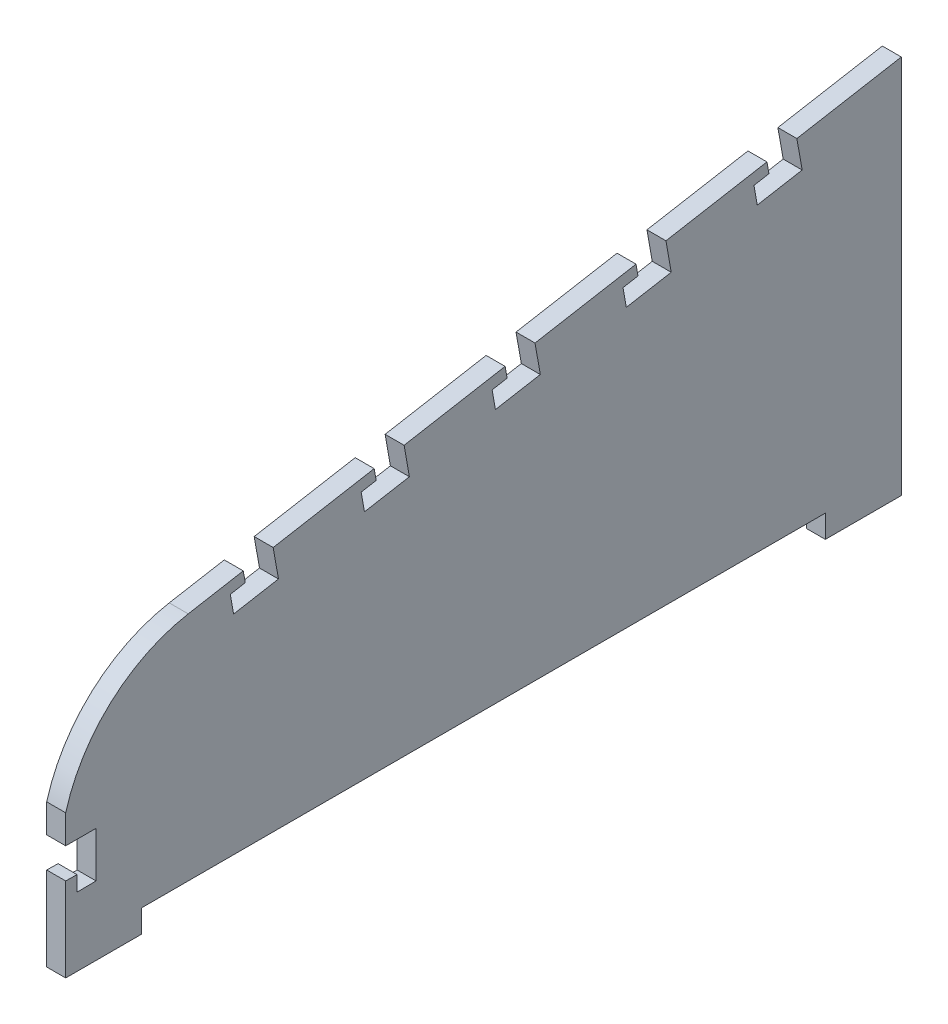
from build123d import *

# Parameters (mm, degrees)
BOSS_EXTRUDE1_DEPTH = 5


with BuildPart() as part:
    # Sketch1 → Boss-Extrude1 (new body)
    with BuildSketch(Plane(origin=(0, 0, 0), x_dir=(0, 0, -1), z_dir=(1, 0, 0))):
        with BuildLine():
            Line((-110, -6), (-90, -6))
            Line((-90, -6), (-90, 0))
            Line((-90, 0), (90, 0))
            Line((90, 0), (90, -6))
            Line((90, -6), (110, -6))
            Line((110, -6), (110, 94))
            Line((110, 94), (82.504621365, 89.151822902))
            Line((82.504621365, 89.151822902), (83.893806786, 81.273360878))
            Line((83.893806786, 81.273360878), (72.07611375, 79.189582746))
            Line((72.07611375, 79.189582746), (71.207872862, 84.113621511))
            Line((71.207872862, 84.113621511), (75.147103874, 84.808214222))
            Line((75.147103874, 84.808214222), (74.626159341, 87.762637481))
            Line((74.626159341, 87.762637481), (48.03635001, 83.074136684))
            Line((48.03635001, 83.074136684), (49.425535431, 75.195674659))
            Line((49.425535431, 75.195674659), (37.607842395, 73.111896527))
            Line((37.607842395, 73.111896527), (36.739601507, 78.035935292))
            Line((36.739601507, 78.035935292), (40.678832519, 78.730528003))
            Line((40.678832519, 78.730528003), (40.157887986, 81.684951262))
            Line((40.157887986, 81.684951262), (13.568078654, 76.996450465))
            Line((13.568078654, 76.996450465), (14.957264076, 69.117988441))
            Line((14.957264076, 69.117988441), (3.139571039, 67.034210309))
            Line((3.139571039, 67.034210309), (2.271330151, 71.958249074))
            Line((2.271330151, 71.958249074), (6.210561163, 72.652841785))
            Line((6.210561163, 72.652841785), (5.68961663, 75.607265044))
            Line((5.68961663, 75.607265044), (-20.900192701, 70.918764247))
            Line((-20.900192701, 70.918764247), (-19.51100728, 63.040302223))
            Line((-19.51100728, 63.040302223), (-31.328700316, 60.956524091))
            Line((-31.328700316, 60.956524091), (-32.196941204, 65.880562856))
            Line((-32.196941204, 65.880562856), (-28.257710192, 66.575155566))
            Line((-28.257710192, 66.575155566), (-28.778654725, 69.529578826))
            Line((-28.778654725, 69.529578826), (-55.368464057, 64.841078029))
            Line((-55.368464057, 64.841078029), (-53.979278635, 56.962616004))
            Line((-53.979278635, 56.962616004), (-65.796971671, 54.878837872))
            Line((-65.796971671, 54.878837872), (-66.66521256, 59.802876637))
            Line((-66.66521256, 59.802876637), (-62.725981548, 60.497469348))
            Line((-62.725981548, 60.497469348), (-63.246926081, 63.451892607))
            Line((-63.246926081, 63.451892607), (-77.735825896, 60.897108649))
            ThreePointArc((-77.735825896, 60.897108649), (-98.082925814, 50.934591362), (-110, 31.66701319))
            Line((-110, 31.66701319), (-110, 24.130960335))
            Line((-110, 24.130960335), (-102, 24.130960335))
            Line((-102, 24.130960335), (-102, 12.130960335))
            Line((-102, 12.130960335), (-106.999710258, 12.07713347))
            Line((-106.999710258, 12.07713347), (-107.000482929, 16.077133396))
            Line((-107.000482929, 16.077133396), (-110, 16.130960335))
            Line((-110, 16.130960335), (-110, -6))
        make_face()
    extrude(amount=BOSS_EXTRUDE1_DEPTH)


solid = part.part
